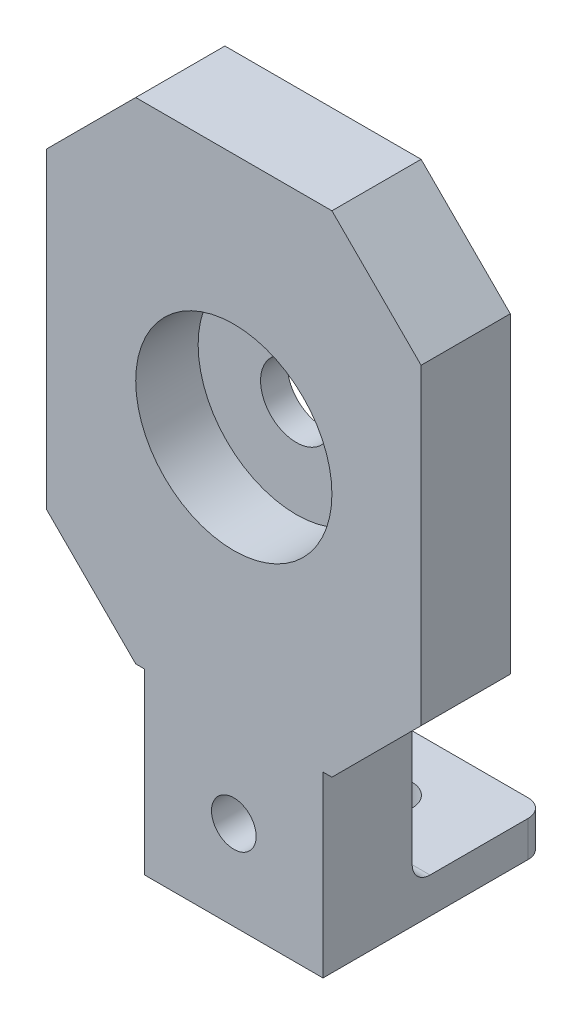
from build123d import *

# Parameters (mm, degrees)
ESTRUSIONE_ESTRUSIONE1_DEPTH = 10
SCHIZZO6_R                   = 11
TAGLIO_ESTRUSIONE4_DEPTH     = 7
SCHIZZO7_R                   = 4
TAGLIO_ESTRUSIONE5_DEPTH     = 4
SMUSSO2_SIZE                 = 10
SCHIZZO8_W                   = 20
SCHIZZO8_H                   = 4
ESTRUSIONE_ESTRUSIONE3_DEPTH = 15
SCHIZZO9_R                   = 2.5
TAGLIO_ESTRUSIONE6_DEPTH     = 35
RACCORDO1_R                  = 2
SCHIZZO10_R                  = 2.5
TAGLIO_ESTRUSIONE7_DEPTH     = 10


with BuildPart() as part:
    # Schizzo1 → Estrusione-Estrusione1 (new body)
    with BuildSketch(Plane.XY):
        Polygon((-10, -47.5), (10, -47.5), (10, -27.5), (21, -27.5), (21, 27.5), (-21, 27.5), (-21, -27.5), (-10, -27.5), align=None)
    extrude(amount=ESTRUSIONE_ESTRUSIONE1_DEPTH)

    # Schizzo6 → Taglio-Estrusione4 (cut)
    with BuildSketch(Plane.XY.offset(10)):
        Circle(SCHIZZO6_R)
    extrude(amount=-TAGLIO_ESTRUSIONE4_DEPTH, mode=Mode.SUBTRACT)

    # Schizzo7 → Taglio-Estrusione5 (cut, through all)
    with BuildSketch(Plane.XY.offset(3)):
        Circle(SCHIZZO7_R)
    extrude(amount=-TAGLIO_ESTRUSIONE5_DEPTH, mode=Mode.SUBTRACT)

    # Smusso2
    smusso2_edges = [part.edges().sort_by_distance(p)[0] for p in [
        (21, -27.5, 5),
        (-21, -27.5, 5),
        (-21, 27.5, 5),
        (21, 27.5, 5),
    ]]
    chamfer(smusso2_edges, length=SMUSSO2_SIZE)

    # Schizzo8 → Estrusione-Estrusione3 (add)
    with BuildSketch(Plane(origin=(0, 0, 0), x_dir=(-1, 0, 0), z_dir=(0, 0, -1))):
        with Locations((0, -45.5)):
            Rectangle(SCHIZZO8_W, SCHIZZO8_H)
    extrude(amount=ESTRUSIONE_ESTRUSIONE3_DEPTH)

    # Schizzo9 → Taglio-Estrusione6 (cut)
    with BuildSketch(Plane(origin=(0, -43.5, 0), x_dir=(1, 0, 0), z_dir=(0, 1, 0))):
        with Locations((0, 7.5)):
            Circle(SCHIZZO9_R)
    extrude(amount=-TAGLIO_ESTRUSIONE6_DEPTH, mode=Mode.SUBTRACT)

    # Raccordo1
    raccordo1_edges = [part.edges().sort_by_distance(p)[0] for p in [
        (0, -43.5, 0),
        (10, -45.5, -15),
        (-10, -45.5, -15),
    ]]
    fillet(raccordo1_edges, radius=RACCORDO1_R)

    # Schizzo10 → Taglio-Estrusione7 (cut)
    with BuildSketch(Plane(origin=(0, 0, 0), x_dir=(-1, 0, 0), z_dir=(0, 0, -1))):
        with Locations((0, -37.5)):
            Circle(SCHIZZO10_R)
    extrude(amount=-TAGLIO_ESTRUSIONE7_DEPTH, mode=Mode.SUBTRACT)


solid = part.part
